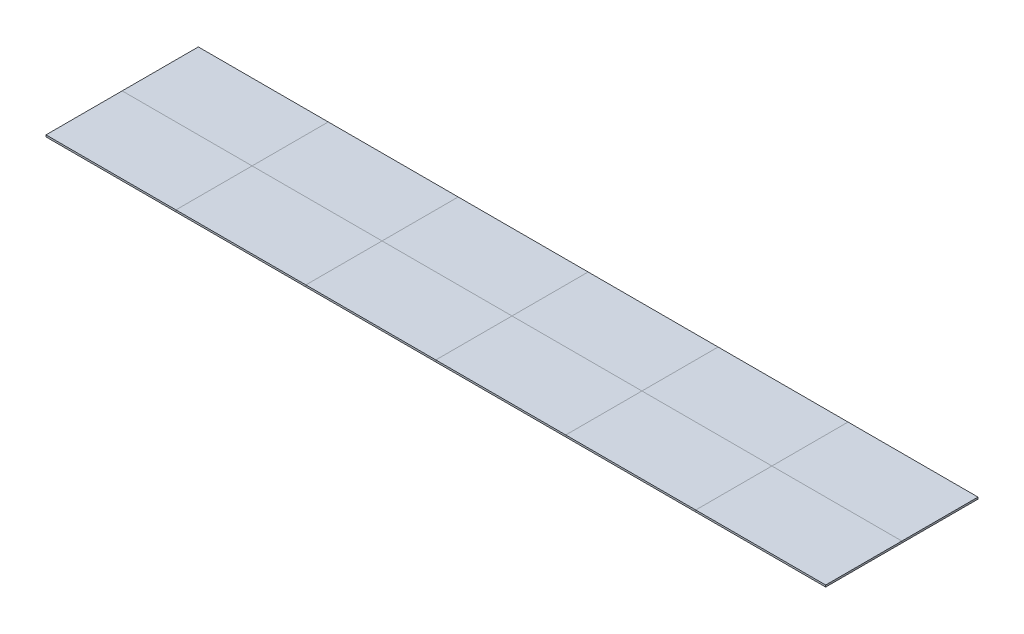
from build123d import *

# Parameters (mm, degrees)
SKETCH1_W                 = 12026.9
SKETCH1_H                 = 2349.5
BOSS_EXTRUDE1_DEPTH       = 27.94
SPLIT1_SURFACE_1_1_BACK   = 12255.275
SPLIT1_SURFACE_1_1_DEPTH  = 24510.55
SPLIT1_SURFACE_1_2_BACK   = 12255.275
SPLIT1_SURFACE_1_2_DEPTH  = 24510.55
SPLIT1_SURFACE_2_3_BACK   = 12255.275
SPLIT1_SURFACE_2_3_DEPTH  = 24510.55
SPLIT1_SURFACE_2_4_BACK   = 12255.275
SPLIT1_SURFACE_2_4_DEPTH  = 24510.55
SPLIT1_SURFACE_2_5_BACK   = 12255.275
SPLIT1_SURFACE_2_5_DEPTH  = 24510.55
SPLIT1_SURFACE_2_6_BACK   = 12255.275
SPLIT1_SURFACE_2_6_DEPTH  = 24510.55
SPLIT1_SURFACE_3_7_BACK   = 12255.275
SPLIT1_SURFACE_3_7_DEPTH  = 24510.55
SPLIT1_SURFACE_3_8_BACK   = 12255.275
SPLIT1_SURFACE_3_8_DEPTH  = 24510.55
SPLIT1_SURFACE_3_9_BACK   = 12255.275
SPLIT1_SURFACE_3_9_DEPTH  = 24510.55
SPLIT1_SURFACE_3_10_BACK  = 12255.275
SPLIT1_SURFACE_3_10_DEPTH = 24510.55
SPLIT1_SURFACE_4_11_BACK  = 12255.275
SPLIT1_SURFACE_4_11_DEPTH = 24510.55
SPLIT1_SURFACE_4_12_BACK  = 12255.275
SPLIT1_SURFACE_4_12_DEPTH = 24510.55
SPLIT1_SURFACE_4_13_BACK  = 12255.275
SPLIT1_SURFACE_4_13_DEPTH = 24510.55
SPLIT1_SURFACE_4_14_BACK  = 12255.275
SPLIT1_SURFACE_4_14_DEPTH = 24510.55
SPLIT1_SURFACE_5_15_BACK  = 12255.275
SPLIT1_SURFACE_5_15_DEPTH = 24510.55
SPLIT1_SURFACE_5_16_BACK  = 12255.275
SPLIT1_SURFACE_5_16_DEPTH = 24510.55
SPLIT1_SURFACE_5_17_BACK  = 12255.275
SPLIT1_SURFACE_5_17_DEPTH = 24510.55
SPLIT1_SURFACE_5_18_BACK  = 12255.275
SPLIT1_SURFACE_5_18_DEPTH = 24510.55
SPLIT1_SURFACE_6_19_BACK  = 12255.275
SPLIT1_SURFACE_6_19_DEPTH = 24510.55
SPLIT1_SURFACE_6_20_BACK  = 12255.275
SPLIT1_SURFACE_6_20_DEPTH = 24510.55
SPLIT1_SURFACE_6_21_BACK  = 12255.275
SPLIT1_SURFACE_6_21_DEPTH = 24510.55
SPLIT1_SURFACE_6_22_BACK  = 12255.275
SPLIT1_SURFACE_6_22_DEPTH = 24510.55


with BuildPart() as part:
    # Sketch1 → Boss-Extrude1 (new body)
    with BuildSketch(Plane(origin=(0, 0, 0), x_dir=(1, 0, 0), z_dir=(0, 1, 0))):
        with Locations((6013.45, 1174.75)):
            Rectangle(SKETCH1_W, SKETCH1_H)
    extrude(amount=-BOSS_EXTRUDE1_DEPTH)


with BuildPart() as body_2:
    # Split1: the piece behind the surface
    add(part.part)
    # Split1 surface 1: a surface, the sketch's curves swept straight by 24510.55 mm
    with BuildLine(Plane(origin=(0, 0, 0), x_dir=(1, 0, 0), z_dir=(0, 1, 0)).offset(-SPLIT1_SURFACE_1_1_BACK), mode=Mode.PRIVATE) as split1_surface_1_1_path:
        Line((0, 1174.75), (12026.9, 1174.75))
    split1_surface_1_1 = Shell.extrude(split1_surface_1_1_path.wire(), (0 * SPLIT1_SURFACE_1_1_DEPTH, 1 * SPLIT1_SURFACE_1_1_DEPTH, 0 * SPLIT1_SURFACE_1_1_DEPTH))
    split(bisect_by=split1_surface_1_1, keep=Keep.BOTTOM)


with BuildPart() as part_1:
    add(part.part)

    # Split1: split by a surface, the side it looks to stays
    # Split1 surface 1: a surface, the sketch's curves swept straight by 24510.55 mm
    with BuildLine(Plane(origin=(0, 0, 0), x_dir=(1, 0, 0), z_dir=(0, 1, 0)).offset(-SPLIT1_SURFACE_1_2_BACK), mode=Mode.PRIVATE) as split1_surface_1_2_path:
        Line((0, 1174.75), (12026.9, 1174.75))
    split1_surface_1_2 = Shell.extrude(split1_surface_1_2_path.wire(), (0 * SPLIT1_SURFACE_1_2_DEPTH, 1 * SPLIT1_SURFACE_1_2_DEPTH, 0 * SPLIT1_SURFACE_1_2_DEPTH))
    split(bisect_by=split1_surface_1_2, keep=Keep.TOP)


with BuildPart() as body_3:
    # Split1 2: the piece behind the surface
    add(part_1.part)
    # Split1 surface 2: a surface, the sketch's curves swept straight by 24510.55 mm
    with BuildLine(Plane(origin=(0, 0, 0), x_dir=(1, 0, 0), z_dir=(0, 1, 0)).offset(-SPLIT1_SURFACE_2_3_BACK), mode=Mode.PRIVATE) as split1_surface_2_3_path:
        Line((2004.483333333, 0), (2004.483333333, 2349.5))
    split1_surface_2_3 = Shell.extrude(split1_surface_2_3_path.wire(), (0 * SPLIT1_SURFACE_2_3_DEPTH, 1 * SPLIT1_SURFACE_2_3_DEPTH, 0 * SPLIT1_SURFACE_2_3_DEPTH))
    split(bisect_by=split1_surface_2_3, keep=Keep.BOTTOM)


with BuildPart() as part_2:
    add(part_1.part)

    # Split1 2: split by a surface, the side it looks to stays
    # Split1 surface 2: a surface, the sketch's curves swept straight by 24510.55 mm
    with BuildLine(Plane(origin=(0, 0, 0), x_dir=(1, 0, 0), z_dir=(0, 1, 0)).offset(-SPLIT1_SURFACE_2_4_BACK), mode=Mode.PRIVATE) as split1_surface_2_4_path:
        Line((2004.483333333, 0), (2004.483333333, 2349.5))
    split1_surface_2_4 = Shell.extrude(split1_surface_2_4_path.wire(), (0 * SPLIT1_SURFACE_2_4_DEPTH, 1 * SPLIT1_SURFACE_2_4_DEPTH, 0 * SPLIT1_SURFACE_2_4_DEPTH))
    split(bisect_by=split1_surface_2_4, keep=Keep.TOP)


with BuildPart() as body_4:
    # Split1 2 body 2: the piece behind the surface
    add(body_2.part)
    # Split1 surface 2: a surface, the sketch's curves swept straight by 24510.55 mm
    with BuildLine(Plane(origin=(0, 0, 0), x_dir=(1, 0, 0), z_dir=(0, 1, 0)).offset(-SPLIT1_SURFACE_2_5_BACK), mode=Mode.PRIVATE) as split1_surface_2_5_path:
        Line((2004.483333333, 0), (2004.483333333, 2349.5))
    split1_surface_2_5 = Shell.extrude(split1_surface_2_5_path.wire(), (0 * SPLIT1_SURFACE_2_5_DEPTH, 1 * SPLIT1_SURFACE_2_5_DEPTH, 0 * SPLIT1_SURFACE_2_5_DEPTH))
    split(bisect_by=split1_surface_2_5, keep=Keep.BOTTOM)


with BuildPart() as body_2_1:
    add(body_2.part)

    # Split1 2 body 2: split by a surface, the side it looks to stays
    # Split1 surface 2: a surface, the sketch's curves swept straight by 24510.55 mm
    with BuildLine(Plane(origin=(0, 0, 0), x_dir=(1, 0, 0), z_dir=(0, 1, 0)).offset(-SPLIT1_SURFACE_2_6_BACK), mode=Mode.PRIVATE) as split1_surface_2_6_path:
        Line((2004.483333333, 0), (2004.483333333, 2349.5))
    split1_surface_2_6 = Shell.extrude(split1_surface_2_6_path.wire(), (0 * SPLIT1_SURFACE_2_6_DEPTH, 1 * SPLIT1_SURFACE_2_6_DEPTH, 0 * SPLIT1_SURFACE_2_6_DEPTH))
    split(bisect_by=split1_surface_2_6, keep=Keep.TOP)


with BuildPart() as body_5:
    # Split1 3 body 3: the piece behind the surface
    add(body_3.part)
    # Split1 surface 3: a surface, the sketch's curves swept straight by 24510.55 mm
    with BuildLine(Plane(origin=(0, 0, 0), x_dir=(1, 0, 0), z_dir=(0, 1, 0)).offset(-SPLIT1_SURFACE_3_7_BACK), mode=Mode.PRIVATE) as split1_surface_3_7_path:
        Line((4008.966666667, 0), (4008.966666667, 2349.5))
    split1_surface_3_7 = Shell.extrude(split1_surface_3_7_path.wire(), (0 * SPLIT1_SURFACE_3_7_DEPTH, 1 * SPLIT1_SURFACE_3_7_DEPTH, 0 * SPLIT1_SURFACE_3_7_DEPTH))
    split(bisect_by=split1_surface_3_7, keep=Keep.BOTTOM)


with BuildPart() as body_3_1:
    add(body_3.part)

    # Split1 3 body 3: split by a surface, the side it looks to stays
    # Split1 surface 3: a surface, the sketch's curves swept straight by 24510.55 mm
    with BuildLine(Plane(origin=(0, 0, 0), x_dir=(1, 0, 0), z_dir=(0, 1, 0)).offset(-SPLIT1_SURFACE_3_8_BACK), mode=Mode.PRIVATE) as split1_surface_3_8_path:
        Line((4008.966666667, 0), (4008.966666667, 2349.5))
    split1_surface_3_8 = Shell.extrude(split1_surface_3_8_path.wire(), (0 * SPLIT1_SURFACE_3_8_DEPTH, 1 * SPLIT1_SURFACE_3_8_DEPTH, 0 * SPLIT1_SURFACE_3_8_DEPTH))
    split(bisect_by=split1_surface_3_8, keep=Keep.TOP)


with BuildPart() as body_6:
    # Split1 3 body 4: the piece behind the surface
    add(body_4.part)
    # Split1 surface 3: a surface, the sketch's curves swept straight by 24510.55 mm
    with BuildLine(Plane(origin=(0, 0, 0), x_dir=(1, 0, 0), z_dir=(0, 1, 0)).offset(-SPLIT1_SURFACE_3_9_BACK), mode=Mode.PRIVATE) as split1_surface_3_9_path:
        Line((4008.966666667, 0), (4008.966666667, 2349.5))
    split1_surface_3_9 = Shell.extrude(split1_surface_3_9_path.wire(), (0 * SPLIT1_SURFACE_3_9_DEPTH, 1 * SPLIT1_SURFACE_3_9_DEPTH, 0 * SPLIT1_SURFACE_3_9_DEPTH))
    split(bisect_by=split1_surface_3_9, keep=Keep.BOTTOM)


with BuildPart() as body_4_1:
    add(body_4.part)

    # Split1 3 body 4: split by a surface, the side it looks to stays
    # Split1 surface 3: a surface, the sketch's curves swept straight by 24510.55 mm
    with BuildLine(Plane(origin=(0, 0, 0), x_dir=(1, 0, 0), z_dir=(0, 1, 0)).offset(-SPLIT1_SURFACE_3_10_BACK), mode=Mode.PRIVATE) as split1_surface_3_10_path:
        Line((4008.966666667, 0), (4008.966666667, 2349.5))
    split1_surface_3_10 = Shell.extrude(split1_surface_3_10_path.wire(), (0 * SPLIT1_SURFACE_3_10_DEPTH, 1 * SPLIT1_SURFACE_3_10_DEPTH, 0 * SPLIT1_SURFACE_3_10_DEPTH))
    split(bisect_by=split1_surface_3_10, keep=Keep.TOP)


with BuildPart() as body_7:
    # Split1 4 body 5: the piece behind the surface
    add(body_5.part)
    # Split1 surface 4: a surface, the sketch's curves swept straight by 24510.55 mm
    with BuildLine(Plane(origin=(0, 0, 0), x_dir=(1, 0, 0), z_dir=(0, 1, 0)).offset(-SPLIT1_SURFACE_4_11_BACK), mode=Mode.PRIVATE) as split1_surface_4_11_path:
        Line((10022.416666667, 0), (10022.416666667, 2349.5))
    split1_surface_4_11 = Shell.extrude(split1_surface_4_11_path.wire(), (0 * SPLIT1_SURFACE_4_11_DEPTH, 1 * SPLIT1_SURFACE_4_11_DEPTH, 0 * SPLIT1_SURFACE_4_11_DEPTH))
    split(bisect_by=split1_surface_4_11, keep=Keep.BOTTOM)


with BuildPart() as body_5_1:
    add(body_5.part)

    # Split1 4 body 5: split by a surface, the side it looks to stays
    # Split1 surface 4: a surface, the sketch's curves swept straight by 24510.55 mm
    with BuildLine(Plane(origin=(0, 0, 0), x_dir=(1, 0, 0), z_dir=(0, 1, 0)).offset(-SPLIT1_SURFACE_4_12_BACK), mode=Mode.PRIVATE) as split1_surface_4_12_path:
        Line((10022.416666667, 0), (10022.416666667, 2349.5))
    split1_surface_4_12 = Shell.extrude(split1_surface_4_12_path.wire(), (0 * SPLIT1_SURFACE_4_12_DEPTH, 1 * SPLIT1_SURFACE_4_12_DEPTH, 0 * SPLIT1_SURFACE_4_12_DEPTH))
    split(bisect_by=split1_surface_4_12, keep=Keep.TOP)


with BuildPart() as body_8:
    # Split1 4 body 6: the piece behind the surface
    add(body_6.part)
    # Split1 surface 4: a surface, the sketch's curves swept straight by 24510.55 mm
    with BuildLine(Plane(origin=(0, 0, 0), x_dir=(1, 0, 0), z_dir=(0, 1, 0)).offset(-SPLIT1_SURFACE_4_13_BACK), mode=Mode.PRIVATE) as split1_surface_4_13_path:
        Line((10022.416666667, 0), (10022.416666667, 2349.5))
    split1_surface_4_13 = Shell.extrude(split1_surface_4_13_path.wire(), (0 * SPLIT1_SURFACE_4_13_DEPTH, 1 * SPLIT1_SURFACE_4_13_DEPTH, 0 * SPLIT1_SURFACE_4_13_DEPTH))
    split(bisect_by=split1_surface_4_13, keep=Keep.BOTTOM)


with BuildPart() as body_6_1:
    add(body_6.part)

    # Split1 4 body 6: split by a surface, the side it looks to stays
    # Split1 surface 4: a surface, the sketch's curves swept straight by 24510.55 mm
    with BuildLine(Plane(origin=(0, 0, 0), x_dir=(1, 0, 0), z_dir=(0, 1, 0)).offset(-SPLIT1_SURFACE_4_14_BACK), mode=Mode.PRIVATE) as split1_surface_4_14_path:
        Line((10022.416666667, 0), (10022.416666667, 2349.5))
    split1_surface_4_14 = Shell.extrude(split1_surface_4_14_path.wire(), (0 * SPLIT1_SURFACE_4_14_DEPTH, 1 * SPLIT1_SURFACE_4_14_DEPTH, 0 * SPLIT1_SURFACE_4_14_DEPTH))
    split(bisect_by=split1_surface_4_14, keep=Keep.TOP)


with BuildPart() as body_9:
    # Split1 5 body 5: the piece behind the surface
    add(body_5_1.part)
    # Split1 surface 5: a surface, the sketch's curves swept straight by 24510.55 mm
    with BuildLine(Plane(origin=(0, 0, 0), x_dir=(1, 0, 0), z_dir=(0, 1, 0)).offset(-SPLIT1_SURFACE_5_15_BACK), mode=Mode.PRIVATE) as split1_surface_5_15_path:
        Line((8017.933333333, 0), (8017.933333333, 2349.5))
    split1_surface_5_15 = Shell.extrude(split1_surface_5_15_path.wire(), (0 * SPLIT1_SURFACE_5_15_DEPTH, 1 * SPLIT1_SURFACE_5_15_DEPTH, 0 * SPLIT1_SURFACE_5_15_DEPTH))
    split(bisect_by=split1_surface_5_15, keep=Keep.BOTTOM)


with BuildPart() as body_5_2:
    add(body_5_1.part)

    # Split1 5 body 5: split by a surface, the side it looks to stays
    # Split1 surface 5: a surface, the sketch's curves swept straight by 24510.55 mm
    with BuildLine(Plane(origin=(0, 0, 0), x_dir=(1, 0, 0), z_dir=(0, 1, 0)).offset(-SPLIT1_SURFACE_5_16_BACK), mode=Mode.PRIVATE) as split1_surface_5_16_path:
        Line((8017.933333333, 0), (8017.933333333, 2349.5))
    split1_surface_5_16 = Shell.extrude(split1_surface_5_16_path.wire(), (0 * SPLIT1_SURFACE_5_16_DEPTH, 1 * SPLIT1_SURFACE_5_16_DEPTH, 0 * SPLIT1_SURFACE_5_16_DEPTH))
    split(bisect_by=split1_surface_5_16, keep=Keep.TOP)


with BuildPart() as body_10:
    # Split1 5 body 6: the piece behind the surface
    add(body_6_1.part)
    # Split1 surface 5: a surface, the sketch's curves swept straight by 24510.55 mm
    with BuildLine(Plane(origin=(0, 0, 0), x_dir=(1, 0, 0), z_dir=(0, 1, 0)).offset(-SPLIT1_SURFACE_5_17_BACK), mode=Mode.PRIVATE) as split1_surface_5_17_path:
        Line((8017.933333333, 0), (8017.933333333, 2349.5))
    split1_surface_5_17 = Shell.extrude(split1_surface_5_17_path.wire(), (0 * SPLIT1_SURFACE_5_17_DEPTH, 1 * SPLIT1_SURFACE_5_17_DEPTH, 0 * SPLIT1_SURFACE_5_17_DEPTH))
    split(bisect_by=split1_surface_5_17, keep=Keep.BOTTOM)


with BuildPart() as body_6_2:
    add(body_6_1.part)

    # Split1 5 body 6: split by a surface, the side it looks to stays
    # Split1 surface 5: a surface, the sketch's curves swept straight by 24510.55 mm
    with BuildLine(Plane(origin=(0, 0, 0), x_dir=(1, 0, 0), z_dir=(0, 1, 0)).offset(-SPLIT1_SURFACE_5_18_BACK), mode=Mode.PRIVATE) as split1_surface_5_18_path:
        Line((8017.933333333, 0), (8017.933333333, 2349.5))
    split1_surface_5_18 = Shell.extrude(split1_surface_5_18_path.wire(), (0 * SPLIT1_SURFACE_5_18_DEPTH, 1 * SPLIT1_SURFACE_5_18_DEPTH, 0 * SPLIT1_SURFACE_5_18_DEPTH))
    split(bisect_by=split1_surface_5_18, keep=Keep.TOP)


with BuildPart() as body_11_2:
    # Split1 6 body 5: the piece behind the surface
    add(body_5_2.part)
    # Split1 surface 6: a surface, the sketch's curves swept straight by 24510.55 mm
    with BuildLine(Plane(origin=(0, 0, 0), x_dir=(1, 0, 0), z_dir=(0, 1, 0)).offset(-SPLIT1_SURFACE_6_19_BACK), mode=Mode.PRIVATE) as split1_surface_6_19_path:
        Line((6013.45, 0), (6013.45, 2349.5))
    split1_surface_6_19 = Shell.extrude(split1_surface_6_19_path.wire(), (0 * SPLIT1_SURFACE_6_19_DEPTH, 1 * SPLIT1_SURFACE_6_19_DEPTH, 0 * SPLIT1_SURFACE_6_19_DEPTH))
    split(bisect_by=split1_surface_6_19, keep=Keep.BOTTOM)


with BuildPart() as body_5_3:
    add(body_5_2.part)

    # Split1 6 body 5: split by a surface, the side it looks to stays
    # Split1 surface 6: a surface, the sketch's curves swept straight by 24510.55 mm
    with BuildLine(Plane(origin=(0, 0, 0), x_dir=(1, 0, 0), z_dir=(0, 1, 0)).offset(-SPLIT1_SURFACE_6_20_BACK), mode=Mode.PRIVATE) as split1_surface_6_20_path:
        Line((6013.45, 0), (6013.45, 2349.5))
    split1_surface_6_20 = Shell.extrude(split1_surface_6_20_path.wire(), (0 * SPLIT1_SURFACE_6_20_DEPTH, 1 * SPLIT1_SURFACE_6_20_DEPTH, 0 * SPLIT1_SURFACE_6_20_DEPTH))
    split(bisect_by=split1_surface_6_20, keep=Keep.TOP)


with BuildPart() as body_12:
    # Split1 6 body 6: the piece behind the surface
    add(body_6_2.part)
    # Split1 surface 6: a surface, the sketch's curves swept straight by 24510.55 mm
    with BuildLine(Plane(origin=(0, 0, 0), x_dir=(1, 0, 0), z_dir=(0, 1, 0)).offset(-SPLIT1_SURFACE_6_21_BACK), mode=Mode.PRIVATE) as split1_surface_6_21_path:
        Line((6013.45, 0), (6013.45, 2349.5))
    split1_surface_6_21 = Shell.extrude(split1_surface_6_21_path.wire(), (0 * SPLIT1_SURFACE_6_21_DEPTH, 1 * SPLIT1_SURFACE_6_21_DEPTH, 0 * SPLIT1_SURFACE_6_21_DEPTH))
    split(bisect_by=split1_surface_6_21, keep=Keep.BOTTOM)


with BuildPart() as body_6_3:
    add(body_6_2.part)

    # Split1 6 body 6: split by a surface, the side it looks to stays
    # Split1 surface 6: a surface, the sketch's curves swept straight by 24510.55 mm
    with BuildLine(Plane(origin=(0, 0, 0), x_dir=(1, 0, 0), z_dir=(0, 1, 0)).offset(-SPLIT1_SURFACE_6_22_BACK), mode=Mode.PRIVATE) as split1_surface_6_22_path:
        Line((6013.45, 0), (6013.45, 2349.5))
    split1_surface_6_22 = Shell.extrude(split1_surface_6_22_path.wire(), (0 * SPLIT1_SURFACE_6_22_DEPTH, 1 * SPLIT1_SURFACE_6_22_DEPTH, 0 * SPLIT1_SURFACE_6_22_DEPTH))
    split(bisect_by=split1_surface_6_22, keep=Keep.TOP)


solid = Compound([part_2.part, body_2_1.part, body_3_1.part, body_4_1.part, body_7.part, body_8.part, body_9.part, body_10.part, body_11_2.part, body_5_3.part, body_12.part, body_6_3.part])
